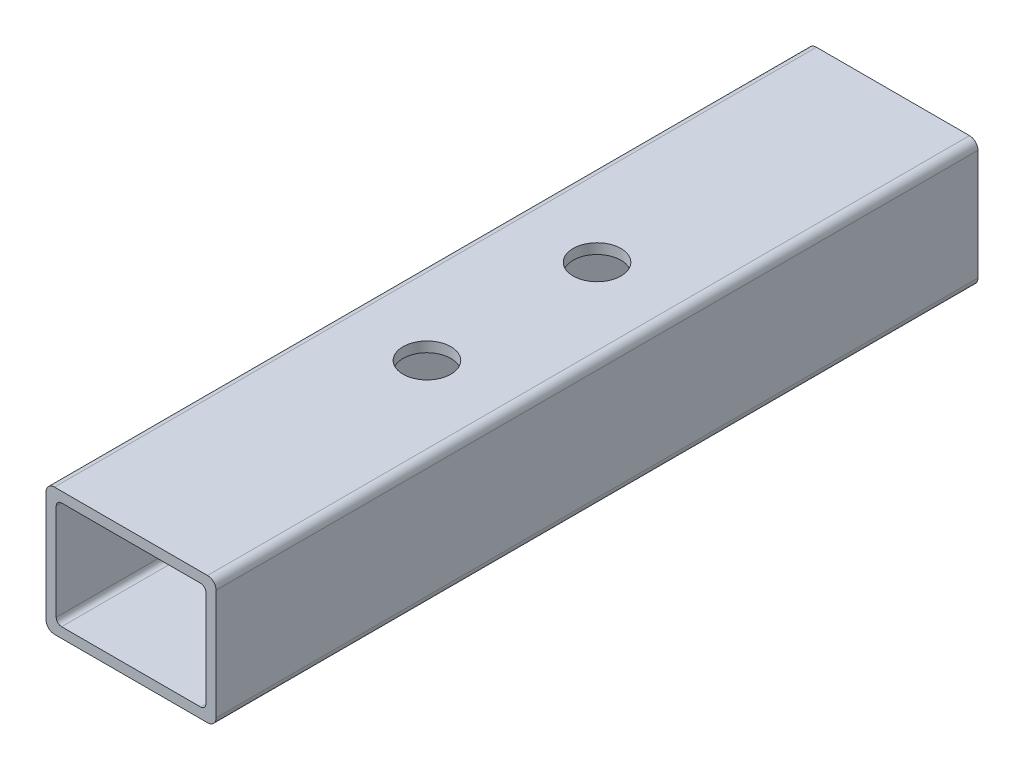
from build123d import *

# Parameters (mm, degrees)
BOSS_EXTRUDE1_DEPTH = 227.56368
SKETCH9_R           = 7.14375
CUT_EXTRUDE2_DEPTH  = 3.048


with BuildPart() as part:
    # Sketch4 → Boss-Extrude1 (new body)
    with BuildSketch(Plane.XY):
        with BuildLine():
            Line((25.4, -16.51), (25.4, 16.51))
            ThreePointArc((25.4, 16.51), (24.656051224, 18.306051224), (22.86, 19.05))
            Line((22.86, 19.05), (-22.86, 19.05))
            ThreePointArc((-22.86, 19.05), (-24.656051224, 18.306051224), (-25.4, 16.51))
            Line((-25.4, 16.51), (-25.4, -16.51))
            ThreePointArc((-25.4, -16.51), (-24.656051224, -18.306051224), (-22.86, -19.05))
            Line((-22.86, -19.05), (22.86, -19.05))
            ThreePointArc((22.86, -19.05), (24.656051224, -18.306051224), (25.4, -16.51))
        make_face()
        with BuildLine():
            Line((22.352, 14.4018), (22.352, -14.4018))
            ThreePointArc((22.352, -14.4018), (21.883312271, -15.533312271), (20.7518, -16.002))
            Line((20.7518, -16.002), (-20.7518, -16.002))
            ThreePointArc((-20.7518, -16.002), (-21.883312271, -15.533312271), (-22.352, -14.4018))
            Line((-22.352, -14.4018), (-22.352, 14.4018))
            ThreePointArc((-22.352, 14.4018), (-21.883312271, 15.533312271), (-20.7518, 16.002))
            Line((-20.7518, 16.002), (20.7518, 16.002))
            ThreePointArc((20.7518, 16.002), (21.883312271, 15.533312271), (22.352, 14.4018))
        make_face(mode=Mode.SUBTRACT)
    extrude(amount=BOSS_EXTRUDE1_DEPTH)

    # Sketch9 → Cut-Extrude2 (cut)
    with BuildSketch(Plane(origin=(0, 19.05, 0), x_dir=(1, 0, 0), z_dir=(0, 1, 0))):
        with Locations((0, -139.18184)):
            Circle(SKETCH9_R)
        with Locations((0, -88.38184)):
            Circle(SKETCH9_R)
    extrude(amount=-CUT_EXTRUDE2_DEPTH, mode=Mode.SUBTRACT)


solid = part.part
